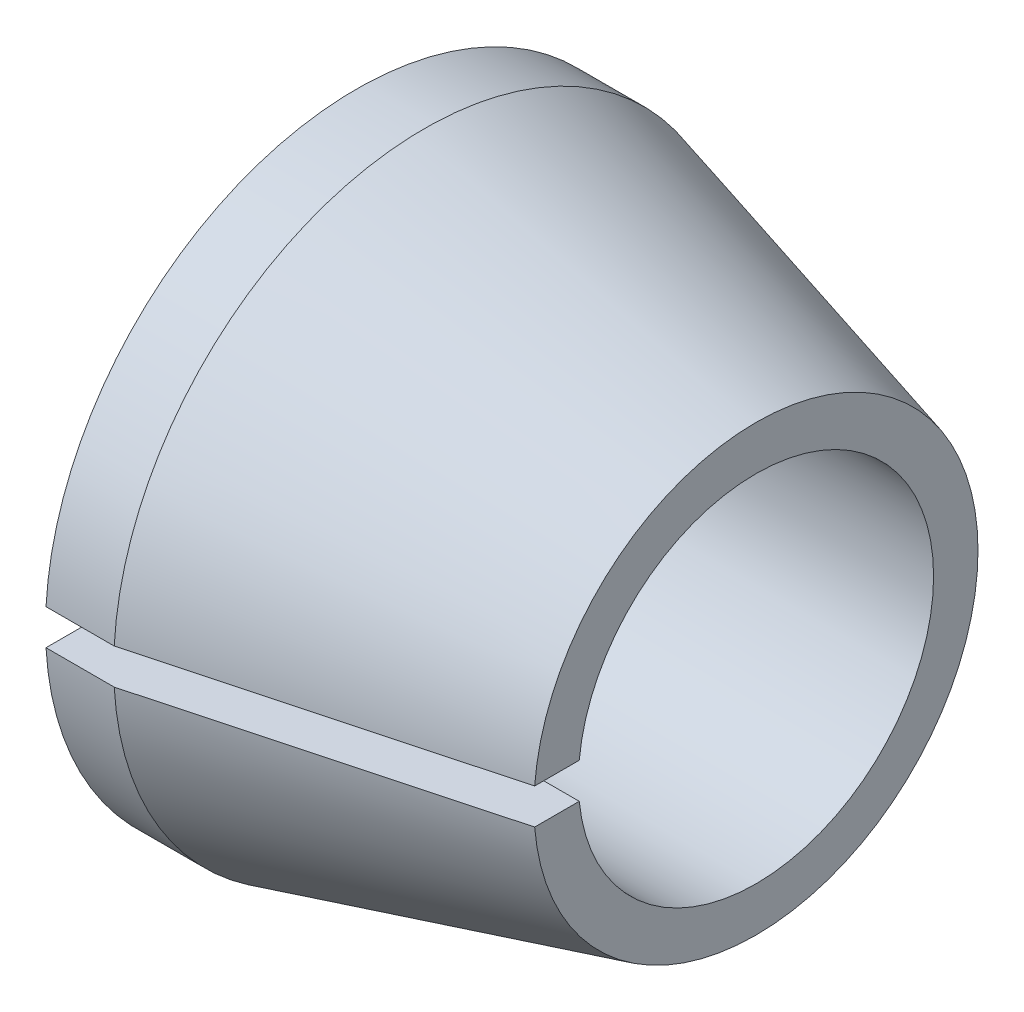
from build123d import *

# Parameters (mm, degrees)
SCHNITT_LINEAR_AUSTRAGEN1_REACH = 11
SKIZZE2_W                       = 6.040100504
SKIZZE2_H                       = 0.8


with BuildPart() as part:
    # Skizze1 → Rotation1 (revolve)
    with BuildSketch(Plane.XY):
        Polygon((0, 4), (9, 4), (9, 5), (1.535898385, 7), (0, 7), align=None)
    revolve(axis=Axis((0, 0, 0), (1, 0, 0)))

    # Skizze2 → Schnitt-Linear austragen1 (cut, up to next)
    with BuildSketch(Plane(origin=(0, 0, 0), x_dir=(0, 0, -1), z_dir=(1, 0, 0)), mode=Mode.PRIVATE) as schnitt_linear_austragen1_sk1:
        with Locations((-7, 0)):
            Rectangle(SKIZZE2_W, SKIZZE2_H)
    schnitt_linear_austragen1_tool1 = extrude(schnitt_linear_austragen1_sk1.sketch, amount=SCHNITT_LINEAR_AUSTRAGEN1_REACH, mode=Mode.PRIVATE) & part.part
    add(schnitt_linear_austragen1_tool1.solids().sort_by_distance((0, 0, 7))[0], mode=Mode.SUBTRACT)


solid = part.part
